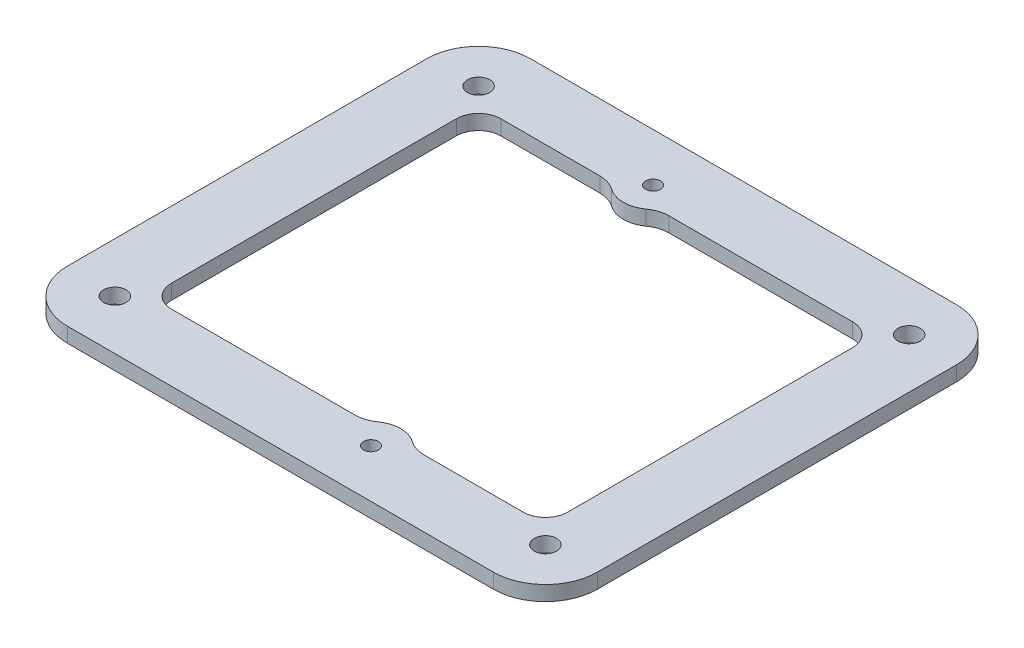
from build123d import *

# Parameters (mm, degrees)
SKETCH_2_R      = 1.5
SKETCH_2_R_2    = 1
EXTRUDE_1_DEPTH = 2
FILLET_1_R      = 7


with BuildPart() as part:
    # 草圖2 → 填料-伸長1 (new body)
    with BuildSketch(Plane(origin=(0, 0, 0), x_dir=(-1, 0, 0), z_dir=(0, 1, 0))):
        Polygon((23.696699141, -31.196699141), (-23.696699141, -31.196699141), (-35.696699141, -31.196699141), (-35.696699141, -19.196699141), (-35.696699141, 19.196699141), (-35.696699141, 31.196699141), (-23.696699141, 31.196699141), (23.696699141, 31.196699141), (35.696699141, 31.196699141), (35.696699141, 19.196699141), (35.696699141, -19.196699141), (35.696699141, -31.196699141), align=None)
        with Locations((29, 24.5)):
            Circle(SKETCH_2_R, mode=Mode.SUBTRACT)
        with Locations((29, -24.5)):
            Circle(SKETCH_2_R, mode=Mode.SUBTRACT)
        with Locations((-29, 24.5)):
            Circle(SKETCH_2_R, mode=Mode.SUBTRACT)
        with Locations((-29, -24.5)):
            Circle(SKETCH_2_R, mode=Mode.SUBTRACT)
        with Locations((5.699998849, -24.700000266)):
            Circle(SKETCH_2_R_2, mode=Mode.SUBTRACT)
        with Locations((-5.700001151, 24.699999734)):
            Circle(SKETCH_2_R_2, mode=Mode.SUBTRACT)
        with BuildLine():
            Line((23.696699141, -22.196699141), (10.359084004, -22.196699141))
            ThreePointArc((10.359084004, -22.196699141), (9.135687554, -22.005019128), (8.029541427, -21.448349703))
            ThreePointArc((8.029541427, -21.448349703), (5.699998849, -20.700000266), (3.370456271, -21.448349703))
            ThreePointArc((3.370456271, -21.448349703), (2.264310144, -22.005019128), (1.040913694, -22.196699141))
            Line((1.040913694, -22.196699141), (-23.696699141, -22.196699141))
            ThreePointArc((-23.696699141, -22.196699141), (-25.818019485, -21.318019485), (-26.696699141, -19.196699141))
            Line((-26.696699141, -19.196699141), (-26.696699141, 19.196699141))
            ThreePointArc((-26.696699141, 19.196699141), (-25.818019485, 21.318019485), (-23.696699141, 22.196699141))
            Line((-23.696699141, 22.196699141), (-10.359087048, 22.196699141))
            ThreePointArc((-10.359087048, 22.196699141), (-9.13569038, 22.005019059), (-8.029544099, 21.448349438))
            ThreePointArc((-8.029544099, 21.448349438), (-5.700001151, 20.699999734), (-3.370458203, 21.448349438))
            ThreePointArc((-3.370458203, 21.448349438), (-2.264311922, 22.005019059), (-1.040915254, 22.196699141))
            Line((-1.040915254, 22.196699141), (23.696699141, 22.196699141))
            ThreePointArc((23.696699141, 22.196699141), (25.818019485, 21.318019485), (26.696699141, 19.196699141))
            Line((26.696699141, 19.196699141), (26.696699141, -19.196699141))
            ThreePointArc((26.696699141, -19.196699141), (25.818019485, -21.318019485), (23.696699141, -22.196699141))
        make_face(mode=Mode.SUBTRACT)
    extrude(amount=EXTRUDE_1_DEPTH)

    # 圓角1
    fillet_1_edges = [part.edges().sort_by_distance(p)[0] for p in [
        (35.696699141, 1, -31.196699141),
        (35.696699141, 1, 31.196699141),
        (-35.696699141, 1, 31.196699141),
        (-35.696699141, 1, -31.196699141),
    ]]
    fillet(fillet_1_edges, radius=FILLET_1_R)


solid = part.part
